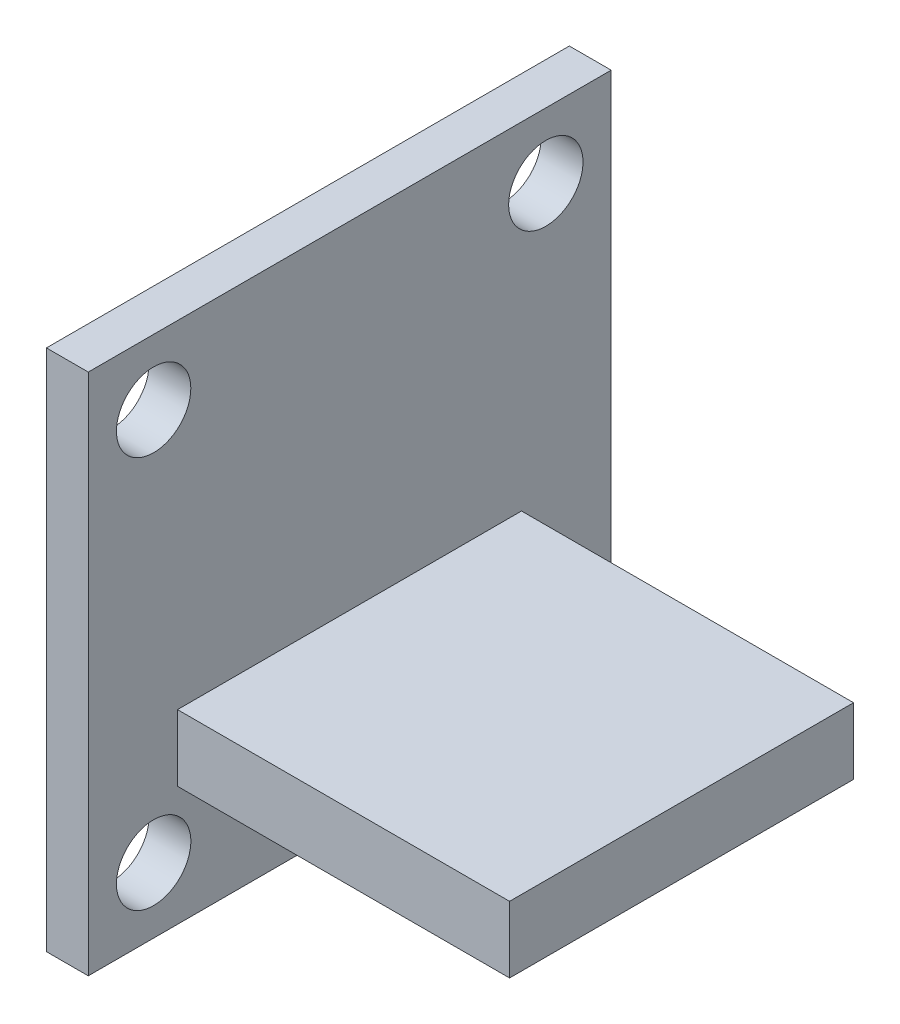
from build123d import *

# Parameters (mm, degrees)
SKETCH1_W          = 20
SKETCH1_H          = 20
EXTRUDE1_DEPTH     = 1.6002
SKETCH2_R          = 1.4224
CUT_EXTRUDE1_DEPTH = 2.6002
SKETCH3_W          = 13.1572
SKETCH3_H          = 2.54
EXTRUDE2_DEPTH     = 12.7


with BuildPart() as part:
    # Sketch1 → Extrude1 (new body)
    with BuildSketch(Plane(origin=(0, 0, 0), x_dir=(0, 0, -1), z_dir=(1, 0, 0))):
        with Locations((10, 10)):
            Rectangle(SKETCH1_W, SKETCH1_H)
    extrude(amount=EXTRUDE1_DEPTH)

    # Sketch2 → Cut-Extrude1 (cut, through all)
    with BuildSketch(Plane(origin=(1.6002, 0, 0), x_dir=(0, 0, -1), z_dir=(1, 0, 0))):
        with Locations((2.5, 17.5)):
            Circle(SKETCH2_R)
        with Locations((17.5, 17.5)):
            Circle(SKETCH2_R)
        with Locations((17.5, 2.5)):
            Circle(SKETCH2_R)
        with Locations((2.5, 2.5)):
            Circle(SKETCH2_R)
    extrude(amount=-CUT_EXTRUDE1_DEPTH, mode=Mode.SUBTRACT)

    # Sketch3 → Extrude2 (add)
    with BuildSketch(Plane(origin=(1.6002, 0, 0), x_dir=(0, 0, -1), z_dir=(1, 0, 0))):
        with Locations((9.9924, 5.842)):
            Rectangle(SKETCH3_W, SKETCH3_H)
    extrude(amount=EXTRUDE2_DEPTH)


solid = part.part
